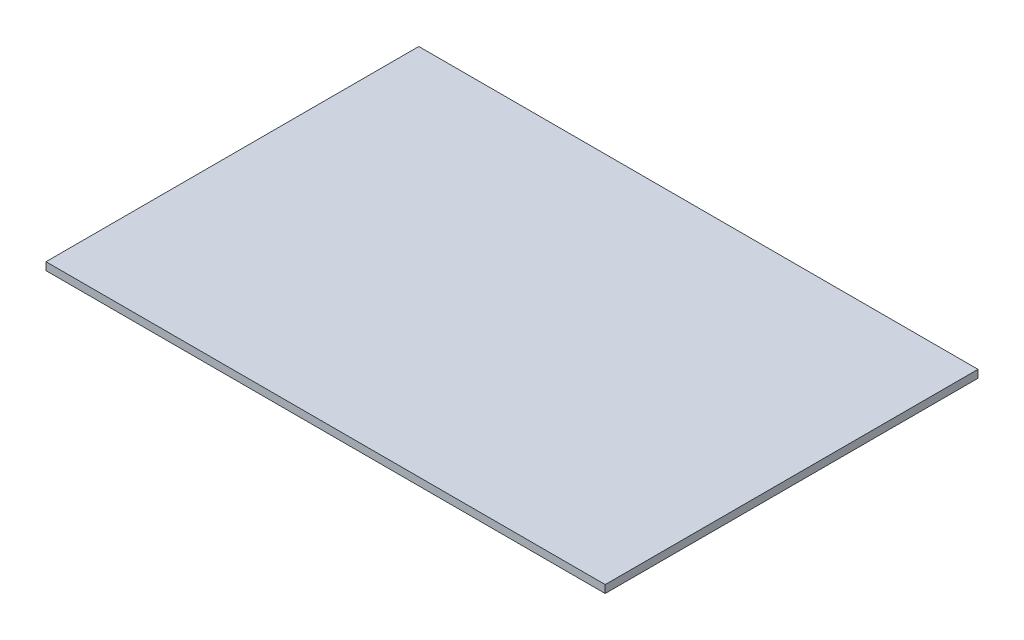
from build123d import *

# Parameters (mm, degrees)
BOX_TOP_SKETCH_W    = 228.6
BOX_TOP_SKETCH_H    = 152.4
BOSS_EXTRUDE1_DEPTH = 3.175


with BuildPart() as part:
    # Box Top Sketch → Boss-Extrude1 (new body)
    with BuildSketch(Plane(origin=(0, 0, 0), x_dir=(1, 0, 0), z_dir=(0, 1, 0))):
        with Locations((114.3, 76.2)):
            Rectangle(BOX_TOP_SKETCH_W, BOX_TOP_SKETCH_H)
    extrude(amount=BOSS_EXTRUDE1_DEPTH)


solid = part.part
